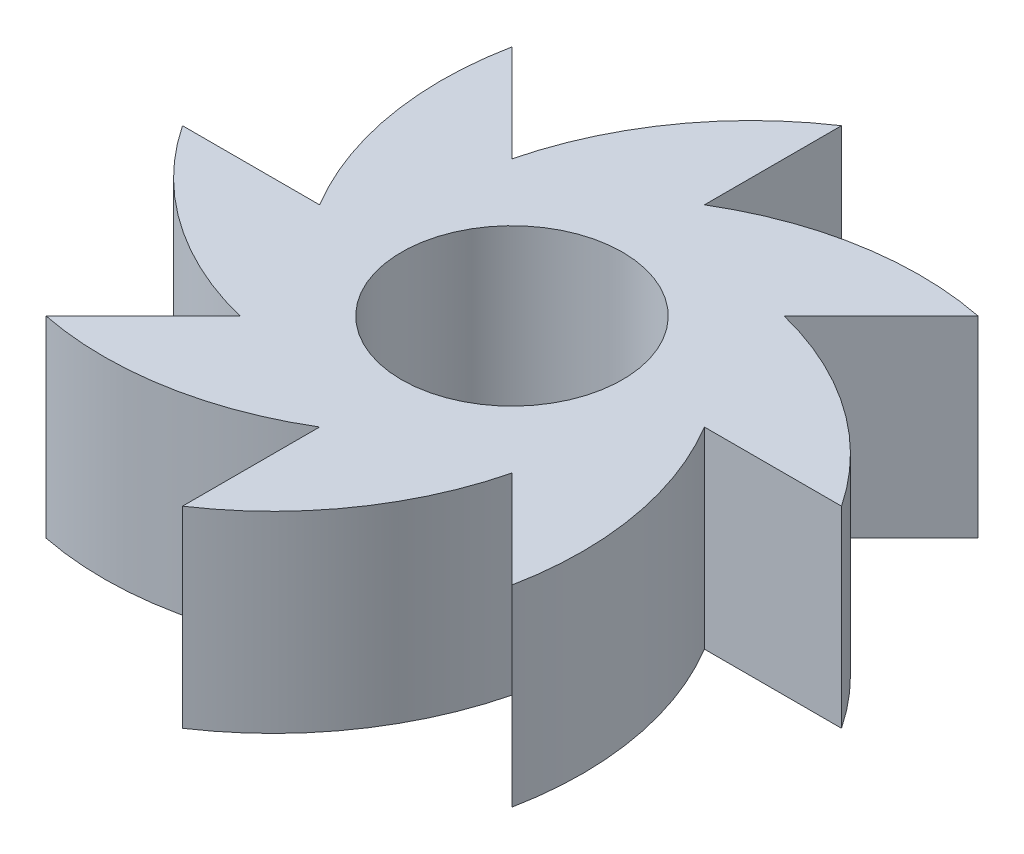
from build123d import *

# Parameters (mm, degrees)
SKETCH_1_R      = 27
EXTRUDE_1_DEPTH = 47


with BuildPart() as part:
    # Эскиз1 → Бобышка-Вытянуть1 (new body)
    with BuildSketch(Plane(origin=(0, 0, 0), x_dir=(1, 0, 0), z_dir=(0, 1, 0))):
        with BuildLine():
            ThreePointArc((47, 0), (33.234018716, 33.234018716), (0, 47))
            ThreePointArc((0, 47), (-33.234018716, 33.234018716), (-47, 0))
            ThreePointArc((-47, 0), (-33.234018716, -33.234018716), (0, -47))
            ThreePointArc((0, -47), (33.234018716, -33.234018716), (47, 0))
        make_face()
        Circle(SKETCH_1_R, mode=Mode.SUBTRACT)
        with BuildLine():
            ThreePointArc((-47, 0), (-43.422338028, 17.986121321), (-33.234018716, 33.234018716))
            Line((-33.234018716, 33.234018716), (-56.922095886, 56.922095886))
            ThreePointArc((-56.922095886, 56.922095886), (-57.279535343, 27.533981904), (-47, 0))
        make_face()
        with BuildLine():
            ThreePointArc((-33.234018716, 33.234018716), (-17.986121321, 43.422338028), (0, 47))
            Line((0, 47), (0, 80.5))
            ThreePointArc((0, 80.5), (-21.033282547, 59.972213182), (-33.234018716, 33.234018716))
        make_face()
        with BuildLine():
            Line((33.234018716, 33.234018716), (56.922095886, 56.922095886))
            ThreePointArc((56.922095886, 56.922095886), (27.533981904, 57.279535343), (0, 47))
            ThreePointArc((0, 47), (17.986121321, 43.422338028), (33.234018716, 33.234018716))
        make_face()
        with BuildLine():
            ThreePointArc((80.5, 0), (59.972213182, 21.033282547), (33.234018716, 33.234018716))
            ThreePointArc((33.234018716, 33.234018716), (43.422338028, 17.986121321), (47, 0))
            Line((47, 0), (80.5, 0))
        make_face()
        with BuildLine():
            ThreePointArc((56.922095886, -56.922095886), (57.279535343, -27.533981904), (47, 0))
            ThreePointArc((47, 0), (43.422338028, -17.986121321), (33.234018716, -33.234018716))
            Line((33.234018716, -33.234018716), (56.922095886, -56.922095886))
        make_face()
        with BuildLine():
            ThreePointArc((0, -80.5), (21.033282547, -59.972213182), (33.234018716, -33.234018716))
            ThreePointArc((33.234018716, -33.234018716), (17.986121321, -43.422338028), (0, -47))
            Line((0, -47), (0, -80.5))
        make_face()
        with BuildLine():
            ThreePointArc((-56.922095886, -56.922095886), (-27.533981904, -57.279535343), (0, -47))
            ThreePointArc((0, -47), (-17.986121321, -43.422338028), (-33.234018716, -33.234018716))
            Line((-33.234018716, -33.234018716), (-56.922095886, -56.922095886))
        make_face()
        with BuildLine():
            ThreePointArc((-33.234018716, -33.234018716), (-43.422338028, -17.986121321), (-47, 0))
            Line((-47, 0), (-80.5, 0))
            ThreePointArc((-80.5, 0), (-59.972213182, -21.033282547), (-33.234018716, -33.234018716))
        make_face()
    extrude(amount=EXTRUDE_1_DEPTH)


solid = part.part
